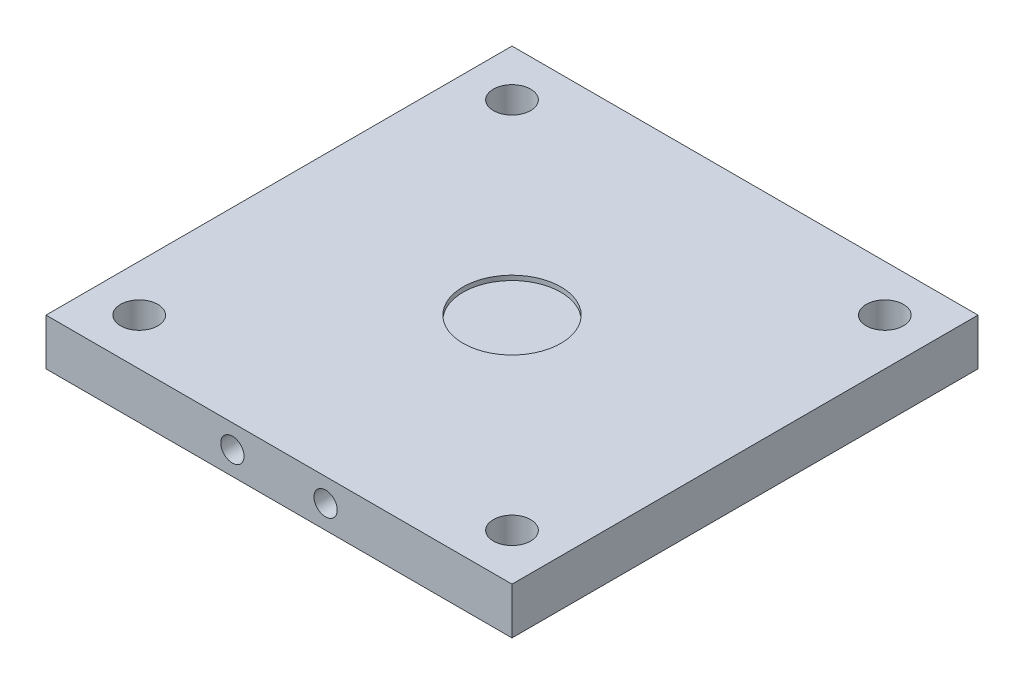
from build123d import *

# Parameters (mm, degrees)
SKETCH1_W           = 100
SKETCH1_H           = 100
BASE_DEPTH          = 10
SKETCH2_R           = 10.5
LOAD_CELL_CUT_DEPTH = 1
CUT_EXTRUDE1_REACH  = 12
SKETCH15_R          = 3
SKETCH21_R          = 2.5
CUT_EXTRUDE2_DEPTH  = 10
SKETCH22_R          = 4
CUT_EXTRUDE3_DEPTH  = 11


with BuildPart() as part:
    # Sketch1 → base (new body)
    with BuildSketch(Plane(origin=(0, 0, 0), x_dir=(1, 0, 0), z_dir=(0, 1, 0))):
        Rectangle(SKETCH1_W, SKETCH1_H)
    extrude(amount=BASE_DEPTH)

    # Sketch2 → load cell cut (cut)
    with BuildSketch(Plane(origin=(0, 10, 0), x_dir=(1, 0, 0), z_dir=(0, 1, 0))):
        Circle(SKETCH2_R)
    extrude(amount=-LOAD_CELL_CUT_DEPTH, mode=Mode.SUBTRACT)

    # Sketch15 → Cut-Extrude1 (cut, up to next)
    with BuildSketch(Plane(origin=(0, 0, 0), x_dir=(-1, 0, 0), z_dir=(0, -1, 0)), mode=Mode.PRIVATE) as cut_extrude1_sk1:
        with Locations((40, -40)):
            Circle(SKETCH15_R)
    cut_extrude1_tool1 = extrude(cut_extrude1_sk1.sketch, amount=-CUT_EXTRUDE1_REACH, mode=Mode.PRIVATE) & part.part
    add(cut_extrude1_tool1.solids().sort_by_distance((-40, 0, 40))[0], mode=Mode.SUBTRACT)
    # Sketch15 → Cut-Extrude1 (cut, up to next)
    with BuildSketch(Plane(origin=(0, 0, 0), x_dir=(-1, 0, 0), z_dir=(0, -1, 0)), mode=Mode.PRIVATE) as cut_extrude1_sk2:
        with Locations((-40, -40)):
            Circle(SKETCH15_R)
    cut_extrude1_tool2 = extrude(cut_extrude1_sk2.sketch, amount=-CUT_EXTRUDE1_REACH, mode=Mode.PRIVATE) & part.part
    add(cut_extrude1_tool2.solids().sort_by_distance((40, 0, 40))[0], mode=Mode.SUBTRACT)
    # Sketch15 → Cut-Extrude1 (cut, up to next)
    with BuildSketch(Plane(origin=(0, 0, 0), x_dir=(-1, 0, 0), z_dir=(0, -1, 0)), mode=Mode.PRIVATE) as cut_extrude1_sk3:
        with Locations((40, 40)):
            Circle(SKETCH15_R)
    cut_extrude1_tool3 = extrude(cut_extrude1_sk3.sketch, amount=-CUT_EXTRUDE1_REACH, mode=Mode.PRIVATE) & part.part
    add(cut_extrude1_tool3.solids().sort_by_distance((-40, 0, -40))[0], mode=Mode.SUBTRACT)
    # Sketch15 → Cut-Extrude1 (cut, up to next)
    with BuildSketch(Plane(origin=(0, 0, 0), x_dir=(-1, 0, 0), z_dir=(0, -1, 0)), mode=Mode.PRIVATE) as cut_extrude1_sk4:
        with Locations((-40, 40)):
            Circle(SKETCH15_R)
    cut_extrude1_tool4 = extrude(cut_extrude1_sk4.sketch, amount=-CUT_EXTRUDE1_REACH, mode=Mode.PRIVATE) & part.part
    add(cut_extrude1_tool4.solids().sort_by_distance((40, 0, -40))[0], mode=Mode.SUBTRACT)

    # Sketch21 → Cut-Extrude2 (cut)
    with BuildSketch(Plane(origin=(0, 0, -50), x_dir=(-1, 0, 0), z_dir=(0, 0, -1))):
        with Locations((-10, 5)):
            Circle(SKETCH21_R)
        with Locations((10, 5)):
            Circle(SKETCH21_R)
    cut_extrude2 = extrude(amount=-CUT_EXTRUDE2_DEPTH, mode=Mode.SUBTRACT)

    # Mirror2: Cut-Extrude2 across plane
    add(cut_extrude2.mirror(Plane.XY), mode=Mode.SUBTRACT)

    # Sketch22 → Cut-Extrude3 (cut, through all)
    with BuildSketch(Plane(origin=(0, 10, 0), x_dir=(1, 0, 0), z_dir=(0, 1, 0))):
        with Locations((40, -40)):
            Circle(SKETCH22_R)
        with Locations((-40, -40)):
            Circle(SKETCH22_R)
        with Locations((-40, 40)):
            Circle(SKETCH22_R)
        with Locations((40, 40)):
            Circle(SKETCH22_R)
    extrude(amount=-CUT_EXTRUDE3_DEPTH, mode=Mode.SUBTRACT)


solid = part.part
